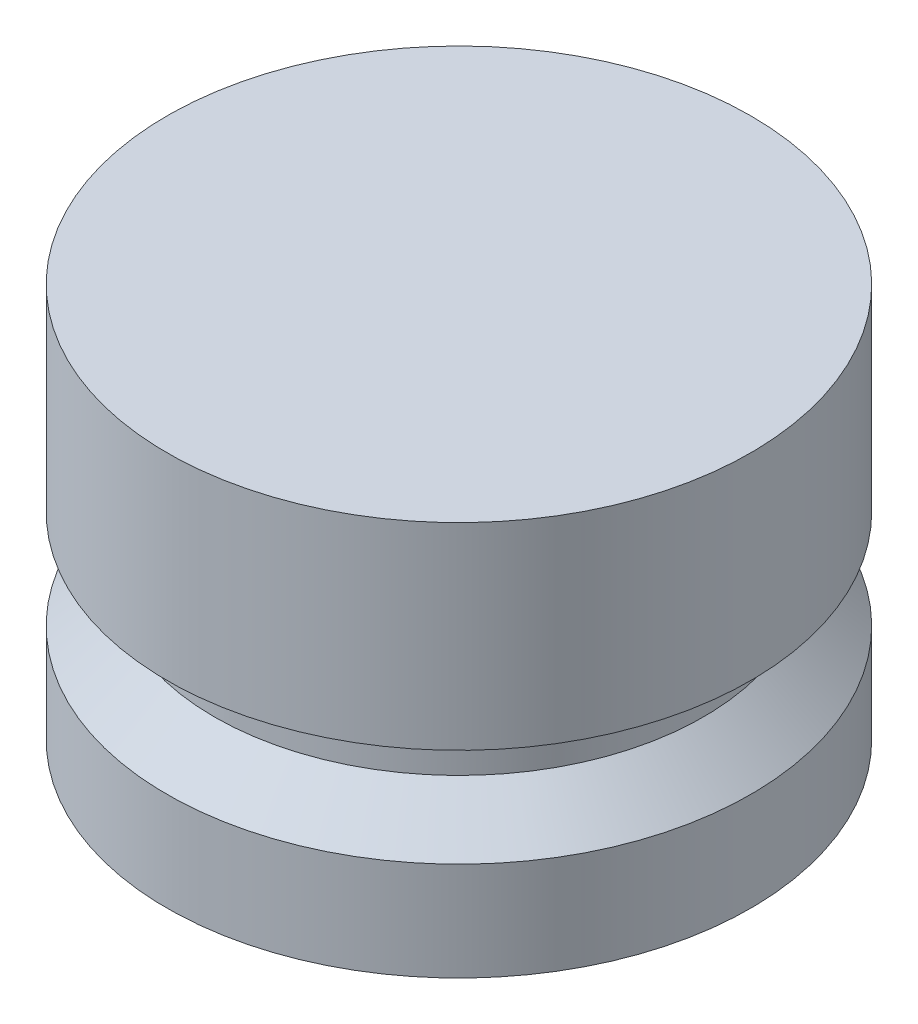
from build123d import *


with BuildPart() as part:
    # Sketch1 → Revolve1 (revolve)
    with BuildSketch(Plane.XY):
        Polygon((0, 0), (-9.398, 0), (-9.398, 3.175), (-7.874, 4.572), (-7.874, 6.35), (-9.398, 6.35), (-9.398, 12.7), (0, 12.7), align=None)
    revolve(axis=Axis((0, 0, 0), (0, 1, 0)))


solid = part.part
